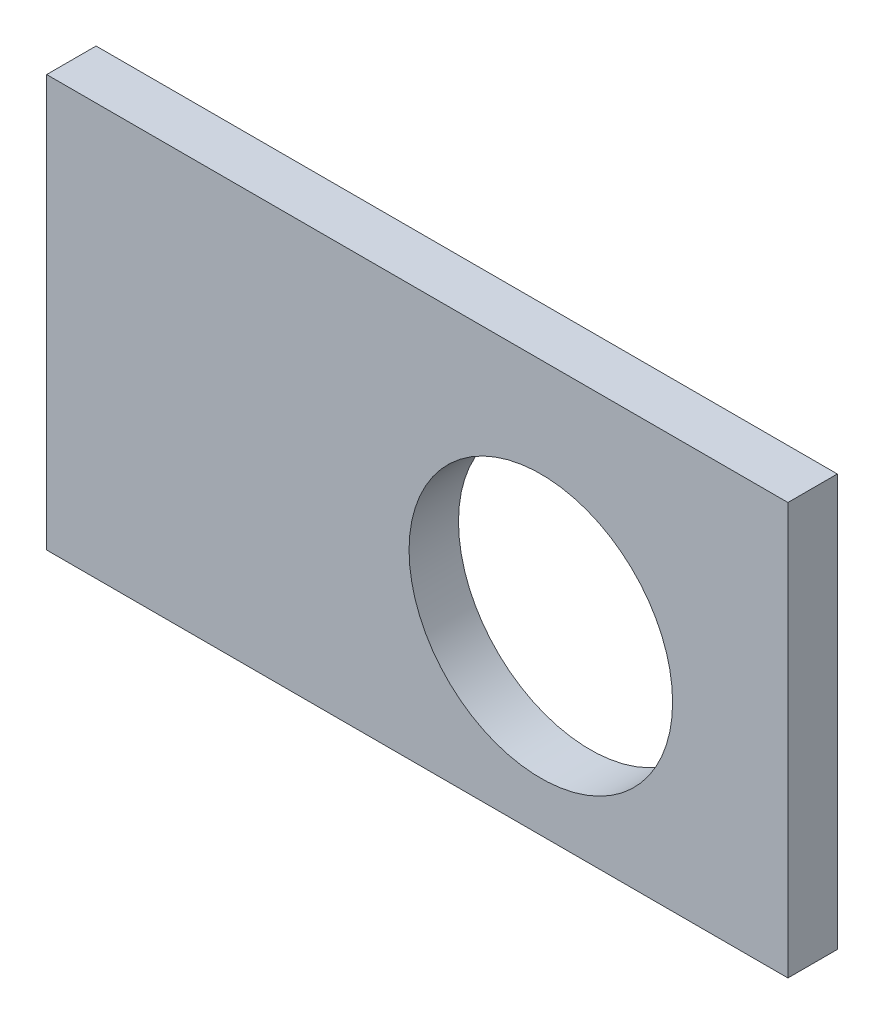
from build123d import *

# Parameters (mm, degrees)
SKETCH1_W           = 90
SKETCH1_H           = 50
SKETCH1_R           = 16
BOSS_EXTRUDE1_DEPTH = 6


with BuildPart() as part:
    # Sketch1 → Boss-Extrude1 (new body)
    with BuildSketch(Plane.XY):
        with Locations((45, 25)):
            Rectangle(SKETCH1_W, SKETCH1_H)
        with Locations((60, 22)):
            Circle(SKETCH1_R, mode=Mode.SUBTRACT)
    extrude(amount=BOSS_EXTRUDE1_DEPTH)


solid = part.part
